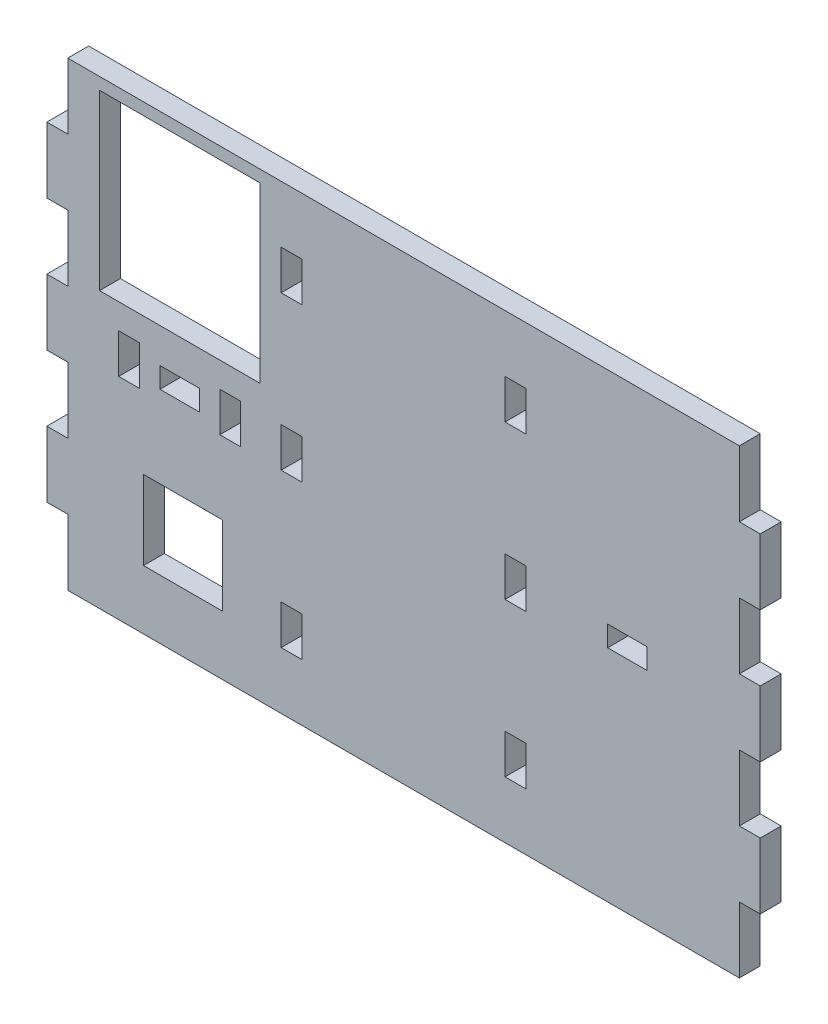
from build123d import *

# Parameters (mm, degrees)
SKETCH1_W           = 3.175
SKETCH1_H           = 6
SKETCH1_W_2         = 6
SKETCH1_H_2         = 3.125
BOSS_EXTRUDE1_DEPTH = 1.5875


with BuildPart() as part:
    # Sketch1 → Boss-Extrude1 (new body, symmetric)
    with BuildSketch(Plane.XY):
        Polygon((54.175, 0), (54.175, 5), (51, 5), (51, 15), (54.175, 15), (54.175, 25), (51, 25), (51, 35), (17, 35), (0, 35), (-17, 35), (-51, 35), (-51, 25), (-54.175, 25), (-54.175, 15), (-51, 15), (-51, 5), (-54.175, 5), (-54.175, -5), (-51, -5), (-51, -15), (-54.175, -15), (-54.175, -25), (-51, -25), (-51, -35), (0, -35), (51, -35), (51, -25), (54.175, -25), (54.175, -15), (51, -15), (51, -5), (54.175, -5), align=None)
        Polygon((-39.5, -14), (-32, -14), (-27.5, -14), (-27.5, -26), (-32, -26), (-39.5, -26), align=None, mode=Mode.SUBTRACT)
        Polygon((-18.5875, -23.333333333), (-18.5875, -20.333333333), (-15.4125, -20.333333333), (-15.4125, -26.333333333), (-18.5875, -26.333333333), align=None, mode=Mode.SUBTRACT)
        Polygon((18.5875, -20.333333333), (18.5875, -23.333333333), (18.5875, -26.333333333), (15.4125, -26.333333333), (15.4125, -20.333333333), align=None, mode=Mode.SUBTRACT)
        with Locations((-41.675, 0)):
            Rectangle(SKETCH1_W, SKETCH1_H, mode=Mode.SUBTRACT)
        with Locations((-34, 0)):
            Rectangle(SKETCH1_W_2, SKETCH1_H_2, mode=Mode.SUBTRACT)
        with Locations((-26.325, 0)):
            Rectangle(SKETCH1_W, SKETCH1_H, mode=Mode.SUBTRACT)
        with Locations((-17, 0)):
            Rectangle(SKETCH1_W, SKETCH1_H, mode=Mode.SUBTRACT)
        Polygon((-46.175, 33.175), (-32, 33.175), (-21.825, 33.175), (-21.825, 6.825), (-34, 6.825), (-46.175, 6.825), align=None, mode=Mode.SUBTRACT)
        Polygon((-18.5875, 20.333333333), (-18.5875, 23.333333333), (-18.5875, 26.333333333), (-15.4125, 26.333333333), (-15.4125, 20.333333333), align=None, mode=Mode.SUBTRACT)
        with Locations((17, 0)):
            Rectangle(SKETCH1_W, SKETCH1_H, mode=Mode.SUBTRACT)
        Polygon((37, 1.5625), (37, 0), (37, -1.5625), (31, -1.5625), (31, 1.5625), align=None, mode=Mode.SUBTRACT)
        Polygon((18.5875, 23.333333333), (18.5875, 20.333333333), (15.4125, 20.333333333), (15.4125, 26.333333333), (18.5875, 26.333333333), align=None, mode=Mode.SUBTRACT)
    extrude(amount=BOSS_EXTRUDE1_DEPTH, both=True)


solid = part.part
